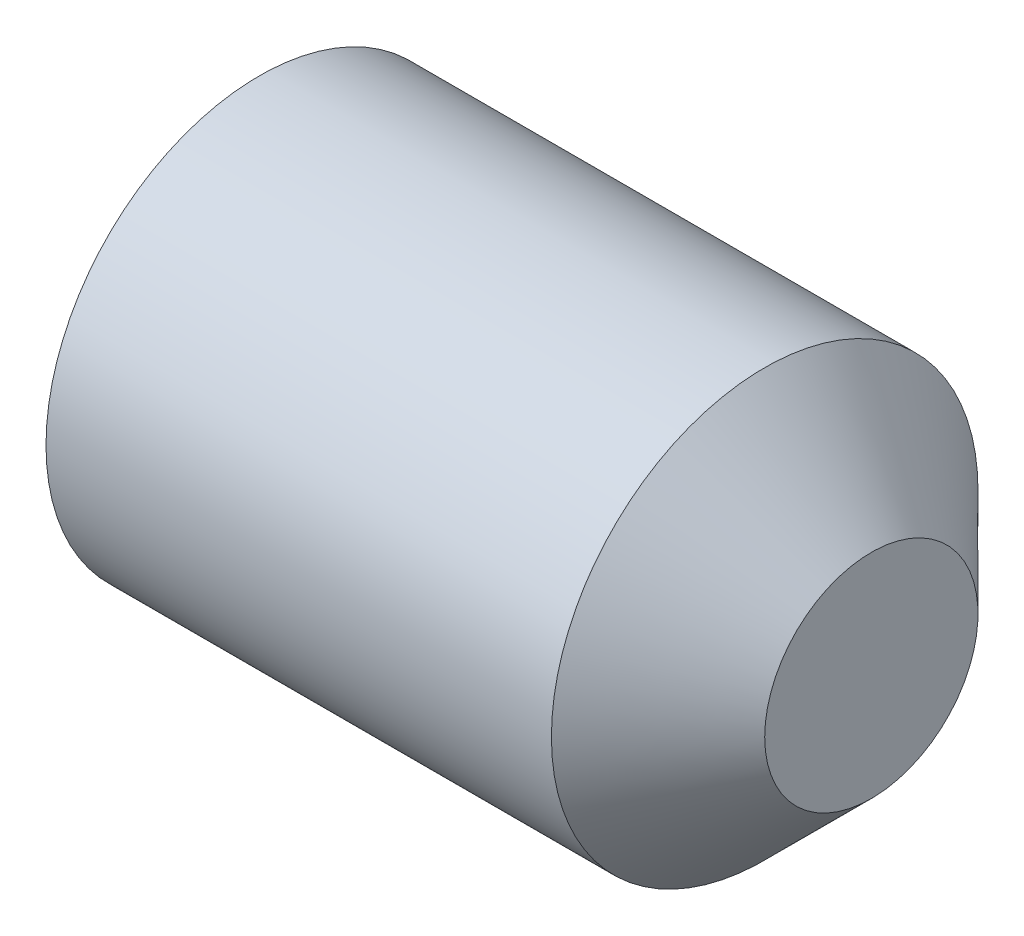
from build123d import *

# Parameters (mm, degrees)
HEX_2_DEPTH = 1.2


with BuildPart() as part:
    # BodySke → BaseBody (revolve)
    with BuildSketch(Plane.XY):
        Polygon((0, 0), (0, 0.774), (0.130481161, 1), (2.5, 1), (3, 0.5), (3, 0), align=None)
    revolve(axis=Axis((-12.7, 0, 0), (1, 0, 0)))

    # Sketch2 → Hex 2 (cut)
    with BuildSketch(Plane.ZY):
        Polygon((0.259807621, 0.45), (-0.259807621, 0.45), (-0.519615242, 0), (-0.259807621, -0.45), (0.259807621, -0.45), (0.519615242, 0), align=None)
    extrude(amount=-HEX_2_DEPTH, mode=Mode.SUBTRACT)


solid = part.part
